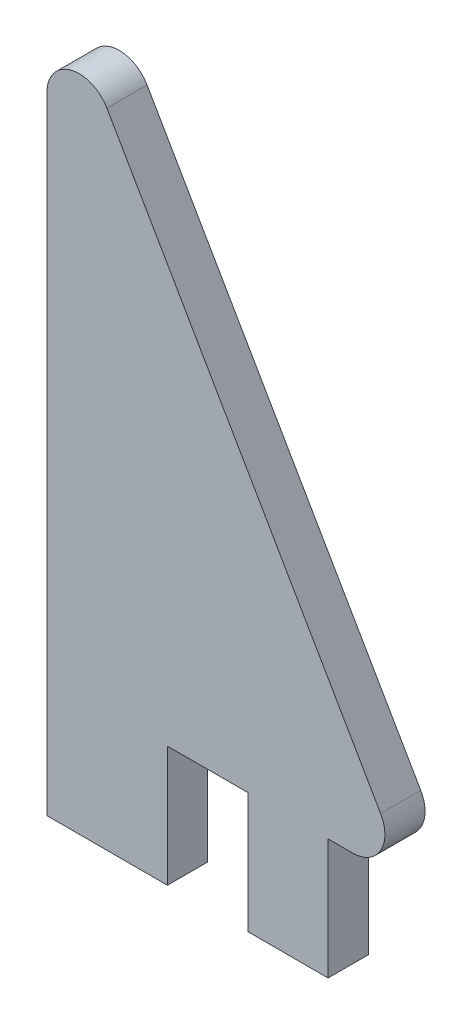
from build123d import *

# Parameters (mm, degrees)
SKETCH1_W           = 9.525
SKETCH1_H           = 9.525
SKETCH1_W_2         = 6.35
BOSS_EXTRUDE1_DEPTH = 3.175
FILLET1_R           = 2.54


with BuildPart() as part:
    # Sketch1 → Boss-Extrude1 (new body)
    with BuildSketch(Plane.XY):
        Polygon((28.575, 0), (0, 0), (0, 49.493351826), align=None)
        with Locations((4.7625, -4.7625)):
            Rectangle(SKETCH1_W, SKETCH1_H)
        with Locations((19.05, -4.7625)):
            Rectangle(SKETCH1_W_2, SKETCH1_H)
    extrude(amount=BOSS_EXTRUDE1_DEPTH)

    # Fillet1
    fillet1_edges = [part.edges().sort_by_distance(p)[0] for p in [
        (0, 49.493351826, 1.5875),
        (28.575, 0, 1.5875),
    ]]
    fillet(fillet1_edges, radius=FILLET1_R)


solid = part.part
